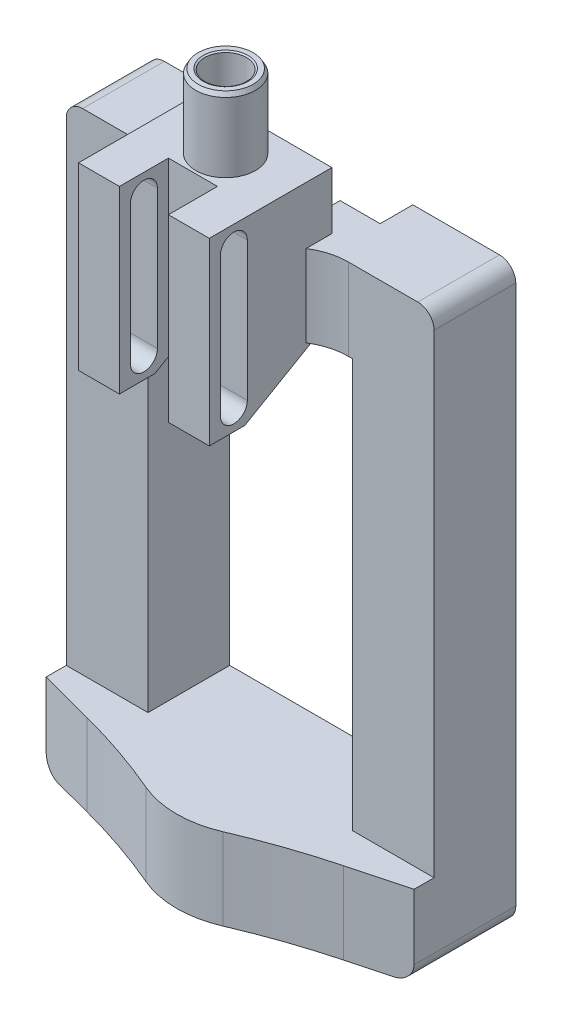
from build123d import *

# Parameters (mm, degrees)
SKETCH2_W               = 45
SKETCH2_H               = 70
SKETCH2_W_2             = 25
SKETCH2_H_2             = 50
BOSS_EXTRUDE2_DEPTH     = 10
CUT_EXTRUDE1_REACH      = 72
BOSS_EXTRUDE3_DEPTH     = 10
SKETCH6_R               = 3.65
BOSS_EXTRUDE4_DEPTH     = 16
BOSS_EXTRUDE5_DEPTH     = 10
BOSS_EXTRUDE8_DEPTH     = 8
SKETCH9_W               = 6
SKETCH9_H               = 22
CUT_EXTRUDE2_DEPTH      = 6
CUT_EXTRUDE3_DEPTH      = 15.5
CUT_EXTRUDE3_DEPTH_BACK = 31.5
SKETCH11_R              = 2.55
CUT_EXTRUDE4_DEPTH      = 13
CHAMFER1_SIZE           = 0.2
CHAMFER1_SIZE2          = 0.115470054
CHAMFER2_SIZE           = 0.5
CHAMFER2_SIZE2          = 0.288675135
FILLET1_R               = 2


with BuildPart() as part:
    # Sketch2 → Boss-Extrude2 (new body)
    with BuildSketch(Plane.XY):
        with Locations((0, 35)):
            Rectangle(SKETCH2_W, SKETCH2_H)
        with Locations((0, 35)):
            Rectangle(SKETCH2_W_2, SKETCH2_H_2, mode=Mode.SUBTRACT)
    extrude(amount=BOSS_EXTRUDE2_DEPTH)

    # Sketch3 → Cut-Extrude1 (cut, up to next)
    with BuildSketch(Plane(origin=(0, 70, 0), x_dir=(1, 0, 0), z_dir=(0, 1, 0)), mode=Mode.PRIVATE) as cut_extrude1_sk1:
        Polygon((-9.9, 0), (-9.9, -4), (-5, -4), (-5, -8), (5, -8), (5, -4), (9.9, -4), (9.9, 0), align=None)
    cut_extrude1_tool1 = extrude(cut_extrude1_sk1.sketch, amount=-CUT_EXTRUDE1_REACH, mode=Mode.PRIVATE) & part.part
    add(cut_extrude1_tool1.solids().sort_by_distance((0, 70, 3.342282))[0], mode=Mode.SUBTRACT)

    # Sketch4 → Boss-Extrude3 (add)
    with BuildSketch(Plane(origin=(0, 70, 0), x_dir=(1, 0, 0), z_dir=(0, 1, 0))):
        with BuildLine():
            Line((-12, -10), (12, -10))
            ThreePointArc((12, -10), (7.5, -11.5), (4.8, -15.4))
            ThreePointArc((4.8, -15.4), (0, -19), (-4.8, -15.4))
            ThreePointArc((-4.8, -15.4), (-7.5, -11.5), (-12, -10))
        make_face()
    extrude(amount=-BOSS_EXTRUDE3_DEPTH)

    # Sketch6 → Boss-Extrude4 (add)
    with BuildSketch(Plane(origin=(0, 70, 0), x_dir=(1, 0, 0), z_dir=(0, 1, 0))):
        with Locations((0, -13)):
            Circle(SKETCH6_R)
    extrude(amount=BOSS_EXTRUDE4_DEPTH)

    # Sketch7 → Boss-Extrude5 (add)
    with BuildSketch(Plane.XZ):
        with BuildLine():
            Line((-22.5, 10), (-22.5, 12.456100996))
            Line((-22.5, 12.456100996), (-15.693142744, 14.258664405))
            ThreePointArc((-15.693142744, 14.258664405), (-10.135286431, 15.948047702), (-4.714257706, 18.035206128))
            ThreePointArc((-4.714257706, 18.035206128), (0, 19), (4.714257706, 18.035206128))
            ThreePointArc((4.714257706, 18.035206128), (10.135286431, 15.948047702), (15.693142744, 14.258664405))
            Line((15.693142744, 14.258664405), (22.5, 12.456100996))
            Line((22.5, 12.456100996), (22.5, 10))
            Line((22.5, 10), (-22.5, 10))
        make_face()
    extrude(amount=-BOSS_EXTRUDE5_DEPTH)

    # Sketch8 → Boss-Extrude8 (add, symmetric)
    with BuildSketch(Plane(origin=(0, 0, 0), x_dir=(0, 0, -1), z_dir=(1, 0, 0))):
        Polygon((-19, 77), (-23, 77), (-23, 55), (-18.660254038, 55), (-10, 60), (-10, 70), (-8, 70), (-8, 77), (-10, 77), align=None)
    extrude(amount=BOSS_EXTRUDE8_DEPTH, both=True)

    # Sketch9 → Cut-Extrude2 (cut)
    with BuildSketch(Plane.XY.offset(23)):
        with Locations((0, 66)):
            Rectangle(SKETCH9_W, SKETCH9_H)
    extrude(amount=-CUT_EXTRUDE2_DEPTH, mode=Mode.SUBTRACT)

    # Sketch10 → Cut-Extrude3 (cut, two sides)
    with BuildSketch(Plane.ZY.offset(8)) as cut_extrude3_sk:
        with BuildLine():
            Line((18.35, 74.5), (18.35, 57.5))
            ThreePointArc((18.35, 57.5), (20, 55.85), (21.65, 57.5))
            Line((21.65, 57.5), (21.65, 74.5))
            ThreePointArc((21.65, 74.5), (20, 76.15), (18.35, 74.5))
        make_face()
    extrude(amount=CUT_EXTRUDE3_DEPTH, mode=Mode.SUBTRACT)
    extrude(cut_extrude3_sk.sketch, amount=-CUT_EXTRUDE3_DEPTH_BACK, mode=Mode.SUBTRACT)

    # Sketch11 → Cut-Extrude4 (cut)
    with BuildSketch(Plane(origin=(0, 86, 0), x_dir=(1, 0, 0), z_dir=(0, 1, 0))):
        with Locations((0, -13)):
            Circle(SKETCH11_R)
    extrude(amount=-CUT_EXTRUDE4_DEPTH, mode=Mode.SUBTRACT)

    # Chamfer1
    chamfer1_edges = [part.edges().sort_by_distance(p)[0] for p in [
        (-2.55, 86, 13),
    ]]
    chamfer1_side = [part.faces().sort_by_distance(p)[0] for p in [
        (-3.54676241, 86, 13),
    ]]
    chamfer(chamfer1_edges, length=CHAMFER1_SIZE, length2=CHAMFER1_SIZE2, reference=chamfer1_side[0])

    # Chamfer2
    chamfer2_edges = [part.edges().sort_by_distance(p)[0] for p in [
        (-3.65, 86, 13),
    ]]
    chamfer2_side = [part.faces().sort_by_distance(p)[0] for p in [
        (-3.65, 81.5, 13),
    ]]
    chamfer(chamfer2_edges, length=CHAMFER2_SIZE, length2=CHAMFER2_SIZE2, reference=chamfer2_side[0])

    # Fillet1
    fillet1_edges = [part.edges().sort_by_distance(p)[0] for p in [
        (-22.5, 70, 5),
        (22.5, 70, 5),
        (22.5, 0, 6.228050498),
        (-22.5, 0, 6.228050498),
    ]]
    fillet(fillet1_edges, radius=FILLET1_R)


solid = part.part
